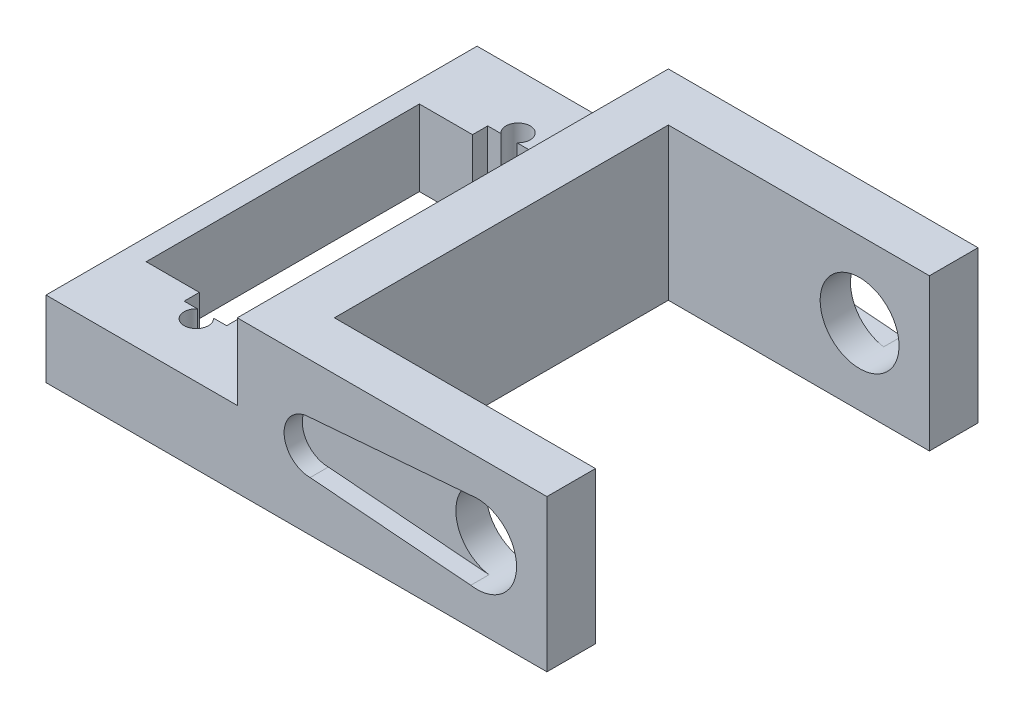
from build123d import *

# Parameters (mm, degrees)
SKETCH1_W           = 41.91
SKETCH1_H           = 36.068
BOSS_EXTRUDE1_DEPTH = 12.7
SKETCH3_W           = 21.844
SKETCH3_H           = 27.94
CUT_EXTRUDE1_DEPTH  = 13.7
SKETCH4_W           = 16.002
SKETCH4_H           = 36.068
CUT_EXTRUDE2_DEPTH  = 6.35
SKETCH5_W           = 12.446
SKETCH5_H           = 22.86
CUT_EXTRUDE3_DEPTH  = 7.35
SKETCH6_R           = 1.016
SKETCH6_W           = 3.556
SKETCH6_H           = 2.54
CUT_EXTRUDE11_DEPTH = 6.35
CUT_EXTRUDE13_DEPTH = 1.524
SKETCH9_R           = 3.302
CUT_EXTRUDE14_DEPTH = 37.068


with BuildPart() as part:
    # Sketch1 → Boss-Extrude1 (new body)
    with BuildSketch(Plane(origin=(0, 0, 0), x_dir=(1, 0, 0), z_dir=(0, 1, 0))):
        Rectangle(SKETCH1_W, SKETCH1_H)
    extrude(amount=BOSS_EXTRUDE1_DEPTH)

    # Sketch3 → Cut-Extrude1 (cut, through all)
    with BuildSketch(Plane(origin=(0, 12.7, 0), x_dir=(1, 0, 0), z_dir=(0, 1, 0))):
        with Locations((10.033, 0)):
            Rectangle(SKETCH3_W, SKETCH3_H)
    extrude(amount=-CUT_EXTRUDE1_DEPTH, mode=Mode.SUBTRACT)

    # Sketch4 → Cut-Extrude2 (cut)
    with BuildSketch(Plane(origin=(0, 12.7, 0), x_dir=(1, 0, 0), z_dir=(0, 1, 0))):
        with Locations((-12.954, 0)):
            Rectangle(SKETCH4_W, SKETCH4_H)
    extrude(amount=-CUT_EXTRUDE2_DEPTH, mode=Mode.SUBTRACT)

    # Sketch5 → Cut-Extrude3 (cut, through all)
    with BuildSketch(Plane(origin=(0, 6.35, 0), x_dir=(1, 0, 0), z_dir=(0, 1, 0))):
        with Locations((-12.954, 0)):
            Rectangle(SKETCH5_W, SKETCH5_H)
    extrude(amount=-CUT_EXTRUDE3_DEPTH, mode=Mode.SUBTRACT)

    # Sketch6 → Cut-Extrude11 (cut)
    with BuildSketch(Plane(origin=(0, 6.35, 0), x_dir=(1, 0, 0), z_dir=(0, 1, 0))):
        with Locations((-12.954, -13.462)):
            Circle(SKETCH6_R)
        with Locations((-12.954, 13.462)):
            Circle(SKETCH6_R)
        with Locations((-12.954, -11.43)):
            Rectangle(SKETCH6_W, SKETCH6_H)
        with Locations((-12.954, 11.43)):
            Rectangle(SKETCH6_W, SKETCH6_H)
    extrude(amount=-CUT_EXTRUDE11_DEPTH, mode=Mode.SUBTRACT)

    # Sketch8 → Cut-Extrude13 (cut)
    with BuildSketch(Plane(origin=(0, 0, -18.034), x_dir=(-1, 0, 0), z_dir=(0, 0, -1))):
        with BuildLine():
            ThreePointArc((-1.143, 4.172598162), (1.034401838, 6.35), (-1.143, 8.527401838))
            Line((-1.143, 8.527401838), (-15.113, 9.652))
            ThreePointArc((-15.113, 9.652), (-18.415, 6.35), (-15.113, 3.048))
            Line((-15.113, 3.048), (-1.143, 4.172598162))
        make_face()
    cut_extrude13 = extrude(amount=-CUT_EXTRUDE13_DEPTH, mode=Mode.SUBTRACT)

    # Mirror1: Cut-Extrude13 across plane
    add(cut_extrude13.mirror(Plane.XY), mode=Mode.SUBTRACT)

    # Sketch9 → Cut-Extrude14 (cut, through all)
    with BuildSketch(Plane(origin=(0, 0, -18.034), x_dir=(-1, 0, 0), z_dir=(0, 0, -1))):
        with Locations((-15.113, 6.35)):
            Circle(SKETCH9_R)
    extrude(amount=-CUT_EXTRUDE14_DEPTH, mode=Mode.SUBTRACT)


solid = part.part
